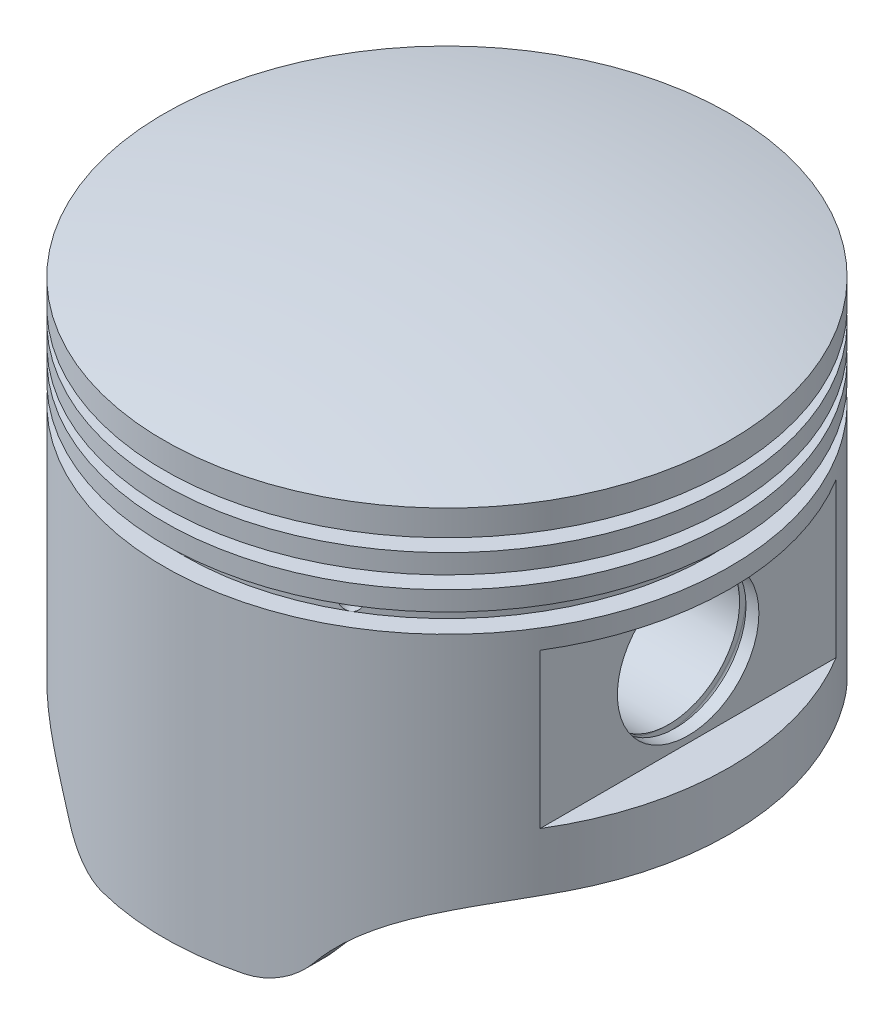
from build123d import *

# Parameters (mm, degrees)
SKETCH2_W               = 13
SKETCH2_H               = 24
CUT_EXTRUDE1_DEPTH      = 45
CUT_EXTRUDE1_DEPTH_BACK = 45
BOSS_EXTRUDE3_DEPTH     = 39
BOSS_EXTRUDE4_DEPTH     = 10
SKETCH5_R               = 11
CUT_EXTRUDE2_DEPTH      = 82.5
DOME1_FACE_RADIUS       = 44
DOME1_HEIGHT            = 5
FILLET1_R               = 2
CUT_EXTRUDE3_DEPTH      = 45
CUT_EXTRUDE3_DEPTH_BACK = 45
FILLET2_R               = 10
SKETCH8_ONE_SIDE_W      = 3
SKETCH8_ONE_SIDE_H      = 3
SKETCH9_R               = 1.5
CUT_EXTRUDE4_DEPTH      = 45.0000001
CIRPATTERN1_COUNT       = 12


with BuildPart() as part:
    # Sketch1 → Revolve1 (revolve)
    with BuildSketch(Plane(origin=(0, 0, 0), x_dir=(0, 0, -1), z_dir=(1, 0, 0))):
        Polygon((0, 59), (0, 67), (44, 67), (44, 63), (41, 63), (41, 61), (44, 61), (44, 58), (41, 58), (41, 56), (44, 56), (44, 0), (41, 0), (41, 20), (36, 20), (36, 59), align=None)
    revolve(axis=Axis((0, 0, 0), (0, 1, 0)))

    # Sketch2 → Cut-Extrude1 (cut, two sides)
    with BuildSketch(Plane.XY) as cut_extrude1_sk:
        with Locations((44, 35)):
            Rectangle(SKETCH2_W, SKETCH2_H)
        with Locations((-44, 35)):
            Rectangle(SKETCH2_W, SKETCH2_H)
    extrude(amount=CUT_EXTRUDE1_DEPTH, mode=Mode.SUBTRACT)
    extrude(cut_extrude1_sk.sketch, amount=-CUT_EXTRUDE1_DEPTH_BACK, mode=Mode.SUBTRACT)

    # Sketch3 → Boss-Extrude3 (add)
    with BuildSketch(Plane.XZ.offset(-20)):
        with BuildLine():
            Line((-30, 19.899748742), (-30, -19.899748742))
            ThreePointArc((-30, -19.899748742), (-36, 0), (-30, 19.899748742))
        make_face()
        with BuildLine():
            Line((30, 19.899748742), (30, -19.899748742))
            ThreePointArc((30, -19.899748742), (36, 0), (30, 19.899748742))
        make_face()
    extrude(amount=-BOSS_EXTRUDE3_DEPTH)

    # Sketch4 → Boss-Extrude4 (add)
    with BuildSketch(Plane(origin=(-30, 0, 0), x_dir=(0, 0, -1), z_dir=(1, 0, 0))):
        with BuildLine():
            Line((-15, 35), (-15, 59))
            Line((-15, 59), (15, 59))
            Line((15, 59), (15, 35))
            ThreePointArc((15, 35), (0, 20), (-15, 35))
        make_face()
    boss_extrude4 = extrude(amount=BOSS_EXTRUDE4_DEPTH)

    # Mirror1: Boss-Extrude4 across plane
    add(boss_extrude4.mirror(Plane(origin=(0, 0, 0), x_dir=(0, 0, 1), z_dir=(1, 0, 0))))

    # Sketch5 → Cut-Extrude2 (cut, through all)
    with BuildSketch(Plane(origin=(37.5, 0, 0), x_dir=(0, 0, -1), z_dir=(1, 0, 0))):
        with Locations((0, 35)):
            Circle(SKETCH5_R)
    extrude(amount=-CUT_EXTRUDE2_DEPTH, mode=Mode.SUBTRACT)

    # Dome1: a dome of height H over a round flat face of radius A is a cap of a sphere of radius (A * A + H * H) / (2 * H)
    dome1_r = (DOME1_FACE_RADIUS * DOME1_FACE_RADIUS + DOME1_HEIGHT * DOME1_HEIGHT) / (2 * DOME1_HEIGHT)
    dome1_base = Plane((0, 67, 0), z_dir=(0, 1, 0))
    with Locations(dome1_base.offset(DOME1_HEIGHT - dome1_r)):
        dome1_ball = Sphere(dome1_r, mode=Mode.PRIVATE)
    add(split(dome1_ball, bisect_by=dome1_base, keep=Keep.TOP, mode=Mode.PRIVATE))

    # Fillet1
    fillet1_edges = [part.edges().sort_by_distance(p)[0] for p in [
        (20, 20, 0),
        (20, 47, 15),
        (20, 47, -15),
        (-20, 20, 0),
        (-20, 47, -15),
        (-20, 47, 15),
    ]]
    fillet(fillet1_edges, radius=FILLET1_R)

    # Sketch6 → Cut-Extrude3 (cut, two sides)
    with BuildSketch(Plane.XY) as cut_extrude3_sk:
        with BuildLine():
            Line((-44, 0), (-44, 14))
            Line((-44, 14), (-39, 14))
            ThreePointArc((-39, 14), (-25.771243445, 10.213203436), (-16.550055679, 0))
            Line((-16.550055679, 0), (-44, 0))
        make_face()
        with BuildLine():
            Line((16.550055679, 0), (44, 0))
            Line((44, 0), (44, 14))
            Line((44, 14), (39, 14))
            ThreePointArc((39, 14), (25.771243445, 10.213203436), (16.550055679, 0))
        make_face()
    extrude(amount=CUT_EXTRUDE3_DEPTH, mode=Mode.SUBTRACT)
    extrude(cut_extrude3_sk.sketch, amount=-CUT_EXTRUDE3_DEPTH_BACK, mode=Mode.SUBTRACT)

    # Fillet2
    fillet2_edges = [part.edges().sort_by_distance(p)[0] for p in [
        (16.550055679, 0, 39.140040567),
        (16.550055679, 0, -39.140040567),
        (-16.550055679, 0, -39.140040567),
        (-16.550055679, 0, 39.140040567),
    ]]
    fillet(fillet2_edges, radius=FILLET2_R)

    # Sketch7 → Cut-Revolve1 (revolve, cut)
    with BuildSketch(Plane.XY):
        with BuildLine():
            Line((34.5, 48), (35.5, 48))
            ThreePointArc((35.5, 48), (35.853553391, 47.853553391), (36, 47.5))
            Line((36, 47.5), (36, 46.5))
            ThreePointArc((36, 46.5), (35.853553391, 46.146446609), (35.5, 46))
            Line((35.5, 46), (34.5, 46))
            ThreePointArc((34.5, 46), (34.146446609, 46.146446609), (34, 46.5))
            Line((34, 46.5), (34, 47.5))
            ThreePointArc((34, 47.5), (34.146446609, 47.853553391), (34.5, 48))
        make_face()
        with BuildLine():
            Line((-36, 47.5), (-36, 46.5))
            ThreePointArc((-36, 46.5), (-35.853553391, 46.146446609), (-35.5, 46))
            Line((-35.5, 46), (-34.5, 46))
            ThreePointArc((-34.5, 46), (-34.146446609, 46.146446609), (-34, 46.5))
            Line((-34, 46.5), (-34, 47.5))
            ThreePointArc((-34, 47.5), (-34.146446609, 47.853553391), (-34.5, 48))
            Line((-34.5, 48), (-35.5, 48))
            ThreePointArc((-35.5, 48), (-35.853553391, 47.853553391), (-36, 47.5))
        make_face()
    revolve(axis=Axis((-37.5, 35, 0), (1, 0, 0)), mode=Mode.SUBTRACT)

    # Sketch8 one side → Cut-Revolve2 (revolve, cut)
    with BuildSketch(Plane(origin=(0, 0, 0), x_dir=(0, 0, -1), z_dir=(1, 0, 0))):
        with Locations((-42.5, 51.5)):
            Rectangle(SKETCH8_ONE_SIDE_W, SKETCH8_ONE_SIDE_H)
    revolve(axis=Axis((0, 47, 0), (0, 1, 0)), mode=Mode.SUBTRACT)

    # Sketch9 → Cut-Extrude4 (cut, through all)
    with BuildSketch(Plane.XY):
        with Locations((0, 51.5)):
            Circle(SKETCH9_R)
    cut_extrude4 = extrude(amount=-CUT_EXTRUDE4_DEPTH, mode=Mode.SUBTRACT)

    # CirPattern1: Cut-Extrude4 ×12 about axis, 6 skipped
    cirpattern1_axis = Axis((0, 67, 0), (0, -1, 0))
    add([cut_extrude4.rotate(cirpattern1_axis, i * 360 / CIRPATTERN1_COUNT) for i in range(1, CIRPATTERN1_COUNT) if i not in (2, 3, 4, 8, 9, 10)], mode=Mode.SUBTRACT)


solid = part.part
